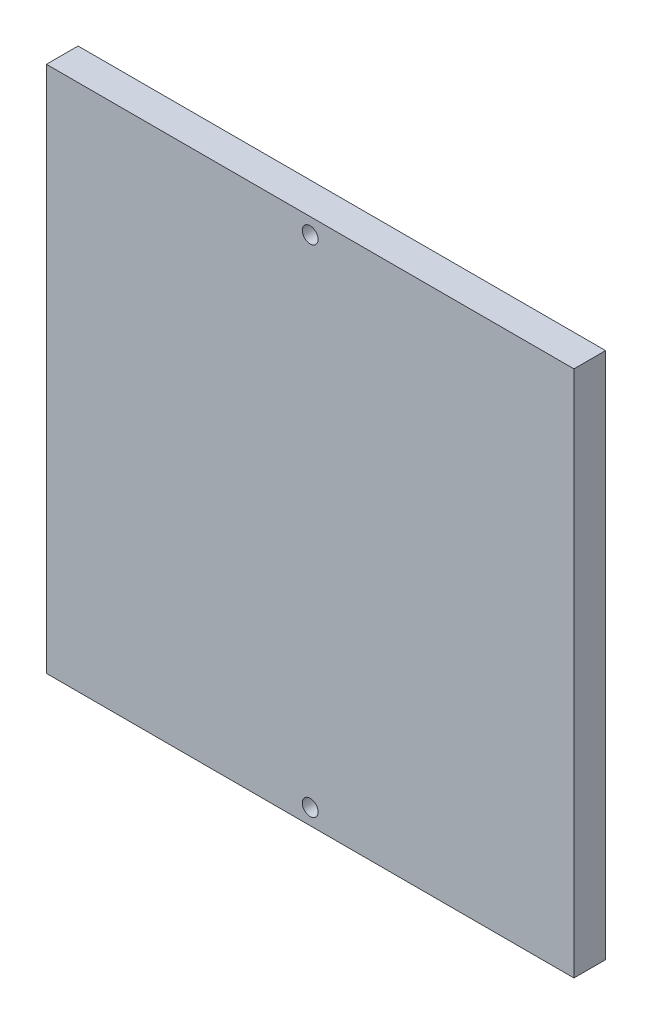
from build123d import *

# Parameters (mm, degrees)
SKETCH1_W           = 100
SKETCH1_H           = 100
SKETCH1_R           = 1.5
BOSS_EXTRUDE1_DEPTH = 6


with BuildPart() as part:
    # Sketch1 → Boss-Extrude1 (new body)
    with BuildSketch(Plane.XY):
        with Locations((50, -88.388923904)):
            Rectangle(SKETCH1_W, SKETCH1_H)
        with Locations((50, -41.388923904)):
            Circle(SKETCH1_R, mode=Mode.SUBTRACT)
        with Locations((50, -135.388923904)):
            Circle(SKETCH1_R, mode=Mode.SUBTRACT)
    extrude(amount=BOSS_EXTRUDE1_DEPTH)


solid = part.part
